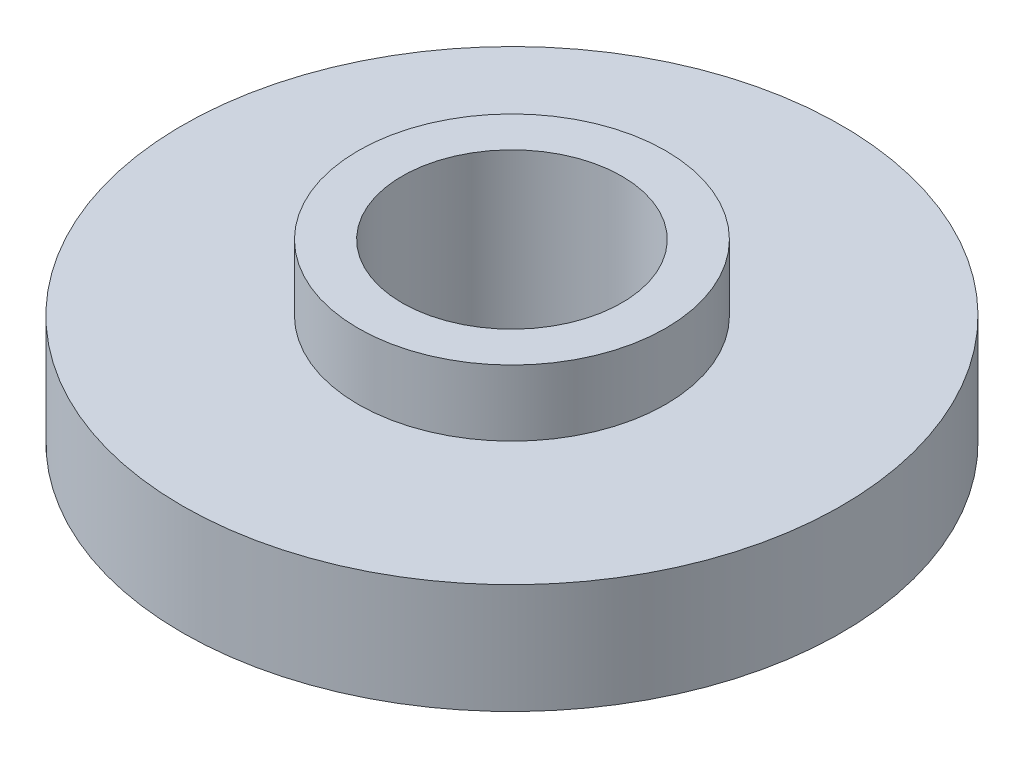
from build123d import *

# Parameters (mm, degrees)
SKETCH1_R           = 7.5
BOSS_EXTRUDE2_DEPTH = 2.5
SKETCH1_6_R         = 2.5
CUT_EXTRUDE1_DEPTH  = 3.5
SKETCH1_7_R         = 3.5
SKETCH1_7_R_2       = 2.5
BOSS_EXTRUDE3_DEPTH = 4


with BuildPart() as part:
    # Sketch1 → Boss-Extrude2 (new body)
    with BuildSketch(Plane(origin=(0, 0, 0), x_dir=(1, 0, 0), z_dir=(0, 1, 0))):
        Circle(SKETCH1_R)
    extrude(amount=BOSS_EXTRUDE2_DEPTH)

    # Sketch1_6 → Cut-Extrude1 (cut)
    with BuildSketch(Plane(origin=(0, 0, 0), x_dir=(1, 0, 0), z_dir=(0, 1, 0))):
        Circle(SKETCH1_6_R)
    extrude(amount=CUT_EXTRUDE1_DEPTH, mode=Mode.SUBTRACT)

    # Sketch1_7 → Boss-Extrude3 (add)
    with BuildSketch(Plane(origin=(0, 0, 0), x_dir=(1, 0, 0), z_dir=(0, 1, 0))):
        Circle(SKETCH1_7_R)
        Circle(SKETCH1_7_R_2, mode=Mode.SUBTRACT)
    extrude(amount=BOSS_EXTRUDE3_DEPTH)


solid = part.part
